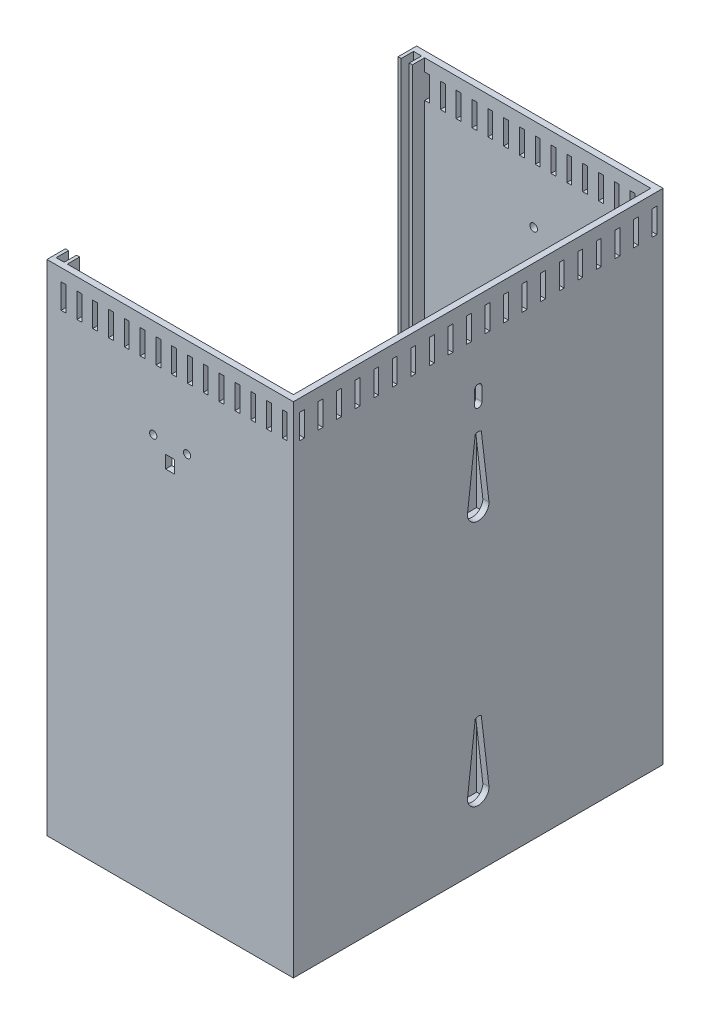
from build123d import *

# Parameters (mm, degrees)
SKETCH1_W            = 101.6
SKETCH1_H            = 152.4
BOSS_EXTRUDE1_DEPTH  = 2.54
BOSS_EXTRUDE2_DEPTH  = 203.2
SKETCH5_W            = 2
SKETCH5_H            = 10.16
CUT_EXTRUDE3_DEPTH   = 2.794
LPATTERN1_COUNT      = 15
LPATTERN1_PITCH      = 6.515571429
SKETCH7_W            = 2
SKETCH7_H            = 10.16
CUT_EXTRUDE4_DEPTH   = 2.794
LPATTERN2_COUNT      = 15
LPATTERN2_PITCH      = 6.515571429
SKETCH9_W            = 2
SKETCH9_H            = 10.16
CUT_EXTRUDE5_DEPTH   = 2.794
LPATTERN4_COUNT      = 20
LPATTERN4_PITCH      = 7.648421053
CUT_EXTRUDE6_DEPTH   = 2.54
SKETCH11_W           = 16.97
SKETCH11_H           = 39.956904613
SKETCH11_W_2         = 13.97
SKETCH11_H_2         = 36.956904613
BOSS_EXTRUDE3_DEPTH  = 5.08
BOSS_EXTRUDE4_DEPTH  = 2.54
LPATTERN5_COUNT      = 2
LPATTERN5_PITCH      = 101.6
LPATTERN6_COUNT      = 2
LPATTERN6_PITCH      = 101.6
LPATTERN7_COUNT      = 2
LPATTERN7_PITCH      = 101.6
CUT_EXTRUDE10_DEPTH  = 12.5
SKETCH18_R           = 24.26335
SKETCH18_R_2         = 1.9939
CUT_EXTRUDE11_DEPTH  = 16.5
SKETCH19_R           = 1.55
CUT_EXTRUDE12_DEPTH  = 16.5
SKETCH20_R           = 1.2
CUT_EXTRUDE13_DEPTH  = 2.54
LPATTERN8_COUNT      = 5
LPATTERN8_PITCH      = 24.892
LPATTERN8_COUNT_DIR2 = 5
LPATTERN8_PITCH_DIR2 = 16.6878
SKETCH24_W           = 7.62
SKETCH24_H           = 16.97
BOSS_EXTRUDE7_DEPTH  = 19.05
CUT_EXTRUDE14_DEPTH  = 28.194
SKETCH26_W           = 7.62
SKETCH26_H           = 16.97
BOSS_EXTRUDE8_DEPTH  = 19.05
CUT_EXTRUDE15_DEPTH  = 18.542
SKETCH14_R           = 1.5
SKETCH14_W           = 3.75000012
SKETCH14_H           = 5.250000168
CUT_EXTRUDE16_DEPTH  = 29.718
SKETCH28_W           = 6
SKETCH28_H           = 94.932
SKETCH28_W_2         = 2
SKETCH28_H_2         = 90.932
BOSS_EXTRUDE10_DEPTH = 5.08
FILLET1_R            = 1.27
CUT_EXTRUDE18_DEPTH  = 3


with BuildPart() as part:
    # Sketch1 → Boss-Extrude1 (new body)
    with BuildSketch(Plane(origin=(0, 0, 0), x_dir=(1, 0, 0), z_dir=(0, 1, 0))):
        with Locations((-40.272368421, 76.2)):
            Rectangle(SKETCH1_W, SKETCH1_H)
    extrude(amount=BOSS_EXTRUDE1_DEPTH)

    # Sketch2 → Boss-Extrude2 (add)
    with BuildSketch(Plane(origin=(0, 2.54, 0), x_dir=(1, 0, 0), z_dir=(0, 1, 0))):
        Polygon((10.527631579, 152.4), (7.987631579, 152.4), (-91.072368421, 152.4), (-91.072368421, 149.86), (-91.072368421, 144.78), (-89.802368421, 144.78), (-89.802368421, 149.86), (-86.500368421, 149.86), (-86.500368421, 144.78), (-85.230368421, 144.78), (-85.230368421, 149.86), (-27.681011237, 149.86), (-26.411011237, 149.86), (7.987631579, 149.86), (7.987631579, 116.331999952), (7.987631579, 115.061999952), (7.987631579, 39.877999952), (7.987631579, 38.607999952), (7.987631579, 2.54), (-26.641011237, 2.54), (-27.911011237, 2.54), (-85.230368421, 2.54), (-85.230368421, 7.62), (-86.500368421, 7.62), (-86.500368421, 2.54), (-89.802368421, 2.54), (-89.802368421, 7.62), (-91.072368421, 7.62), (-91.072368421, 2.54), (-91.072368421, 0), (7.987631579, 0), (10.527631579, 0), align=None)
    extrude(amount=BOSS_EXTRUDE2_DEPTH)

    # Sketch5 → Cut-Extrude3 (cut)
    with BuildSketch(Plane(origin=(0, 0, -152.4), x_dir=(-1, 0, 0), z_dir=(0, 0, -1))):
        with Locations((-6.987631579, 195.58)):
            Rectangle(SKETCH5_W, SKETCH5_H)
    cut_extrude3 = extrude(amount=-CUT_EXTRUDE3_DEPTH, mode=Mode.SUBTRACT)

    # LPattern1: Cut-Extrude3 ×15
    with Locations(*[(-i * LPATTERN1_PITCH, 0, 0) for i in range(1, LPATTERN1_COUNT)]):
        add(cut_extrude3, mode=Mode.SUBTRACT)

    # Sketch7 → Cut-Extrude4 (cut)
    with BuildSketch(Plane.XY):
        with Locations((6.987631579, 195.58)):
            Rectangle(SKETCH7_W, SKETCH7_H)
    cut_extrude4 = extrude(amount=-CUT_EXTRUDE4_DEPTH, mode=Mode.SUBTRACT)

    # LPattern2: Cut-Extrude4 ×15
    with Locations(*[(-i * LPATTERN2_PITCH, 0, 0) for i in range(1, LPATTERN2_COUNT)]):
        add(cut_extrude4, mode=Mode.SUBTRACT)

    # Sketch9 → Cut-Extrude5 (cut)
    with BuildSketch(Plane(origin=(10.527631579, 0, 0), x_dir=(0, 0, -1), z_dir=(1, 0, 0))):
        with Locations((148.86, 195.58)):
            Rectangle(SKETCH9_W, SKETCH9_H)
    cut_extrude5 = extrude(amount=-CUT_EXTRUDE5_DEPTH, mode=Mode.SUBTRACT)

    # LPattern4: Cut-Extrude5 ×20
    with Locations(*[(0, 0, i * LPATTERN4_PITCH) for i in range(1, LPATTERN4_COUNT)]):
        add(cut_extrude5, mode=Mode.SUBTRACT)

    # Sketch10 → Cut-Extrude6 (cut)
    with BuildSketch(Plane(origin=(10.527631579, 0, 0), x_dir=(0, 0, -1), z_dir=(1, 0, 0))):
        with BuildLine():
            Line((71.755, 129.54), (74.961605082, 156.551025148))
            ThreePointArc((74.961605082, 156.551025148), (76.219688657, 156.971904613), (77.469380337, 156.526725421))
            Line((77.469380337, 156.526725421), (80.645, 129.54))
            ThreePointArc((80.645, 129.54), (76.2, 125.095), (71.755, 129.54))
        make_face()
    cut_extrude6 = extrude(amount=-CUT_EXTRUDE6_DEPTH, mode=Mode.SUBTRACT)

    # Sketch11 → Boss-Extrude3 (add)
    with BuildSketch(Plane.ZY.offset(-7.987631579)):
        with Locations((-76.2, 141.033452307)):
            Rectangle(SKETCH11_W, SKETCH11_H)
        with Locations((-76.2, 141.033452307)):
            Rectangle(SKETCH11_W_2, SKETCH11_H_2, mode=Mode.SUBTRACT)
    boss_extrude3 = extrude(amount=BOSS_EXTRUDE3_DEPTH)

    # 3DSketch1 → Boss-Extrude4 (add)
    with BuildSketch(Plane(origin=(2.907631579, 161.011904613, -84.685), x_dir=(0, -0.9204277812363368, 0.3909126494862429), z_dir=(-1, 0, 0))):
        Polygon((0, 0), (6.633787662, 15.619659448), (43.41123272, 0), (36.777445058, -15.619659448), align=None)
    boss_extrude4 = extrude(amount=BOSS_EXTRUDE4_DEPTH)

    # LPattern5: Cut-Extrude6 ×2
    with Locations(*[(0, -i * LPATTERN5_PITCH, 0) for i in range(1, LPATTERN5_COUNT)]):
        add(cut_extrude6, mode=Mode.SUBTRACT)

    # LPattern6: Boss-Extrude3 ×2
    with Locations(*[(0, -i * LPATTERN6_PITCH, 0) for i in range(1, LPATTERN6_COUNT)]):
        add(boss_extrude3)

    # LPattern7: Boss-Extrude4 ×2
    with Locations(*[(0, -i * LPATTERN7_PITCH, 0) for i in range(1, LPATTERN7_COUNT)]):
        add(boss_extrude4)

    # Sketch17 → Cut-Extrude10 (cut)
    with BuildSketch(Plane(origin=(0, 0, -152.4), x_dir=(-1, 0, 0), z_dir=(0, 0, -1))):
        Polygon((-1.637631579, 17.62), (0.862368421, 17.62), (0.862368421, 20.12), (20.362368421, 20.12), (20.362368421, 17.62), (22.862368421, 17.62), (22.862368421, 10.12), (20.362368421, 10.12), (20.362368421, 7.62), (0.862368421, 7.62), (0.862368421, 10.12), (-1.637631579, 10.12), align=None)
    extrude(amount=-CUT_EXTRUDE10_DEPTH, mode=Mode.SUBTRACT)

    # Sketch18 → Cut-Extrude11 (cut)
    with BuildSketch(Plane(origin=(0, 0, -152.4), x_dir=(-1, 0, 0), z_dir=(0, 0, -1))):
        with Locations((57.642368421, 29.62)):
            Circle(SKETCH18_R)
        with Locations((35.642368421, 51.62)):
            Circle(SKETCH18_R_2)
        with Locations((79.642368421, 51.62)):
            Circle(SKETCH18_R_2)
        with Locations((35.642368421, 7.62)):
            Circle(SKETCH18_R_2)
        with Locations((79.642368421, 7.62)):
            Circle(SKETCH18_R_2)
    extrude(amount=-CUT_EXTRUDE11_DEPTH, mode=Mode.SUBTRACT)

    # Sketch19 → Cut-Extrude12 (cut)
    with BuildSketch(Plane(origin=(0, 0, -152.4), x_dir=(-1, 0, 0), z_dir=(0, 0, -1))):
        with Locations((40.272368421, 167.64)):
            Circle(SKETCH19_R)
    extrude(amount=-CUT_EXTRUDE12_DEPTH, mode=Mode.SUBTRACT)

    # Sketch20 → Cut-Extrude13 (cut)
    with BuildSketch(Plane(origin=(0, 2.54, 0), x_dir=(1, 0, 0), z_dir=(0, 1, 0))):
        with Locations((-8.700168421, 124.968)):
            Circle(SKETCH20_R)
    cut_extrude13 = extrude(amount=-CUT_EXTRUDE13_DEPTH, mode=Mode.SUBTRACT)

    # LPattern8: Cut-Extrude13 5 × 5
    with Locations(*[(-j * LPATTERN8_PITCH_DIR2, 0, i * LPATTERN8_PITCH) for i in range(LPATTERN8_COUNT) for j in range(LPATTERN8_COUNT_DIR2) if (i, j) != (0, 0)]):
        add(cut_extrude13, mode=Mode.SUBTRACT)

    # Sketch24 → Boss-Extrude7 (add)
    with BuildSketch(Plane.XZ.offset(-121.055)):
        with Locations((4.177631579, -76.2)):
            Rectangle(SKETCH24_W, SKETCH24_H)
    extrude(amount=BOSS_EXTRUDE7_DEPTH)

    # Sketch25 → Cut-Extrude14 (cut)
    with BuildSketch(Plane(origin=(0, 0, -84.685), x_dir=(-1, 0, 0), z_dir=(0, 0, -1))):
        Polygon((-0.367631579, 102.005), (-0.367631579, 120.674164613), (-7.987631579, 102.005), align=None)
    extrude(amount=-CUT_EXTRUDE14_DEPTH, mode=Mode.SUBTRACT)

    # Sketch26 → Boss-Extrude8 (add)
    with BuildSketch(Plane.XZ.offset(-19.455)):
        with Locations((4.177631579, -76.2)):
            Rectangle(SKETCH26_W, SKETCH26_H)
    extrude(amount=BOSS_EXTRUDE8_DEPTH)

    # Sketch27 → Cut-Extrude15 (cut)
    with BuildSketch(Plane(origin=(0, 0, -84.685), x_dir=(-1, 0, 0), z_dir=(0, 0, -1))):
        Polygon((-0.367631579, 2.54), (-0.367631579, 19.074164613), (-7.987631579, 2.54), align=None)
    extrude(amount=-CUT_EXTRUDE15_DEPTH, mode=Mode.SUBTRACT)

    # Sketch14 → Cut-Extrude16 (cut)
    with BuildSketch(Plane.XY):
        with Locations((-47.257368421, 165.1)):
            Circle(SKETCH14_R)
        with Locations((-33.287368421, 165.1)):
            Circle(SKETCH14_R)
        with Locations((-40.272368421, 157.988)):
            Rectangle(SKETCH14_W, SKETCH14_H)
    extrude(amount=-CUT_EXTRUDE16_DEPTH, mode=Mode.SUBTRACT)

    # Sketch28 → Boss-Extrude10 (add)
    with BuildSketch(Plane(origin=(0, 2.54, 0), x_dir=(1, 0, 0), z_dir=(0, 1, 0))):
        with Locations((-0.632368421, 76.2)):
            Rectangle(SKETCH28_W, SKETCH28_H)
        with Locations((-0.632368421, 76.2)):
            Rectangle(SKETCH28_W_2, SKETCH28_H_2, mode=Mode.SUBTRACT)
    extrude(amount=BOSS_EXTRUDE10_DEPTH)

    # Fillet1
    fillet1_edges = [part.edges().sort_by_distance(p)[0] for p in [
        (-0.632368421, 7.62, -30.734),
        (-0.632368421, 7.62, -121.666),
        (-1.632368421, 7.62, -76.2),
        (0.367631579, 7.62, -76.2),
    ]]
    fillet(fillet1_edges, radius=FILLET1_R)

    # Sketch29 → Cut-Extrude18 (cut)
    with BuildSketch(Plane(origin=(10.527631579, 0, 0), x_dir=(0, 0, -1), z_dir=(1, 0, 0))):
        with BuildLine():
            Line((77.7, 172.466), (77.7, 166.878))
            ThreePointArc((77.7, 166.878), (76.2, 165.378), (74.7, 166.878))
            Line((74.7, 166.878), (74.7, 172.466))
            ThreePointArc((74.7, 172.466), (76.2, 173.966), (77.7, 172.466))
        make_face()
    extrude(amount=-CUT_EXTRUDE18_DEPTH, mode=Mode.SUBTRACT)


solid = part.part
